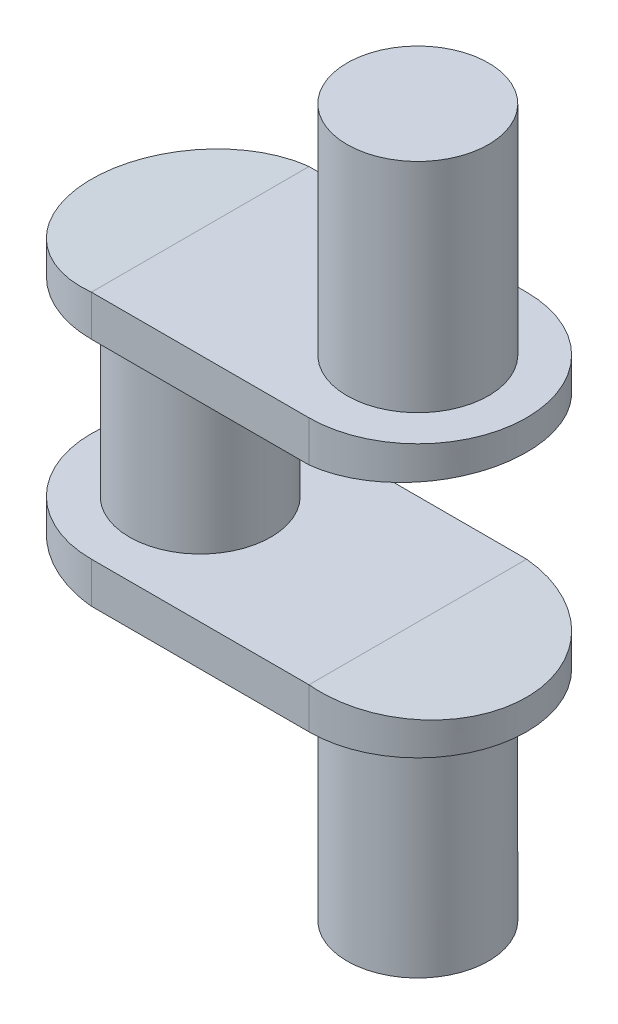
from build123d import *

# Parameters (mm, degrees)
SKETCH1_R               = 26
BOSS_EXTRUDE1_DEPTH     = 35
BOSS_EXTRUDE2_DEPTH     = 15
SKETCH3_R               = 26
BOSS_EXTRUDE3_DEPTH     = 80
CUT_EXTRUDE1_DEPTH      = 41
CUT_EXTRUDE1_DEPTH_BACK = 41


with BuildPart() as part:
    # Sketch1 → Boss-Extrude1 (new body, symmetric)
    with BuildSketch(Plane(origin=(0, 0, 0), x_dir=(1, 0, 0), z_dir=(0, 1, 0))):
        Circle(SKETCH1_R)
    extrude(amount=BOSS_EXTRUDE1_DEPTH, both=True)

    # Sketch2 → Boss-Extrude2 (add)
    with BuildSketch(Plane.XZ.offset(35)):
        with BuildLine():
            Line((0, 40), (80, 40))
            ThreePointArc((80, 40), (120, 0), (80, -40))
            Line((80, -40), (0, -40))
            ThreePointArc((0, -40), (-40, 0), (0, 40))
        make_face()
    boss_extrude2 = extrude(amount=BOSS_EXTRUDE2_DEPTH)

    # Mirror1: Boss-Extrude2 across plane
    add(boss_extrude2.mirror(Plane.ZX))

    # Sketch3 → Boss-Extrude3 (add)
    with BuildSketch(Plane(origin=(0, 50, 0), x_dir=(1, 0, 0), z_dir=(0, 1, 0))):
        with Locations((80, 0)):
            Circle(SKETCH3_R)
    boss_extrude3 = extrude(amount=BOSS_EXTRUDE3_DEPTH)

    # Mirror2: Boss-Extrude3 across plane
    add(boss_extrude3.mirror(Plane.ZX))

    # Sketch4 → Cut-Extrude1 (cut, two sides)
    with BuildSketch(Plane.XY) as cut_extrude1_sk:
        Polygon((0, -50), (-40, -50), (-40, -46), align=None)
        Polygon((80, -35), (120, -35), (120, -39), align=None)
        Polygon((120, 39), (80, 35), (120, 35), align=None)
        Polygon((-40, 46), (0, 50), (-40, 50), align=None)
    extrude(amount=CUT_EXTRUDE1_DEPTH, mode=Mode.SUBTRACT)
    extrude(cut_extrude1_sk.sketch, amount=-CUT_EXTRUDE1_DEPTH_BACK, mode=Mode.SUBTRACT)


solid = part.part
